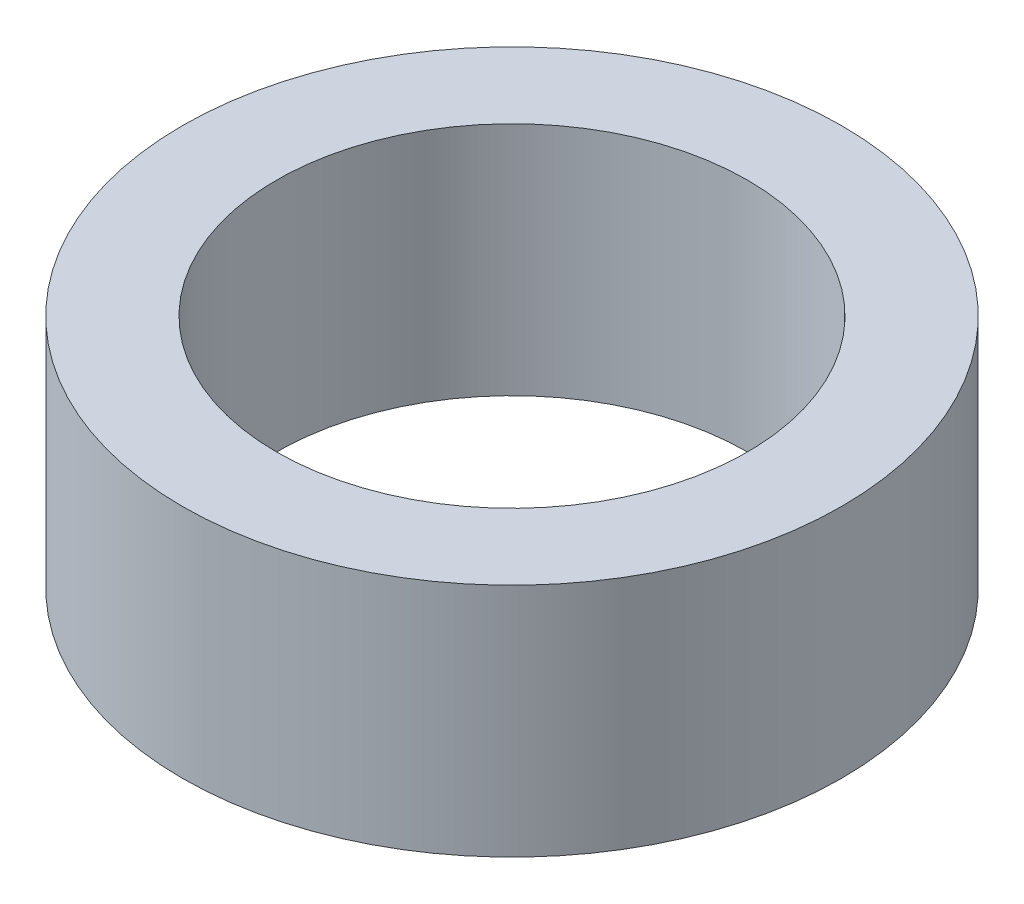
from build123d import *

# Parameters (mm, degrees)
SKETCH1_W = 1.27
SKETCH1_H = 3.175


with BuildPart() as part:
    # Sketch1 → Revolve1 (revolve)
    with BuildSketch(Plane.XY):
        with Locations((-3.81, -1.5875)):
            Rectangle(SKETCH1_W, SKETCH1_H)
    revolve(axis=Axis((0, 0, 0), (0, -1, 0)))


solid = part.part
